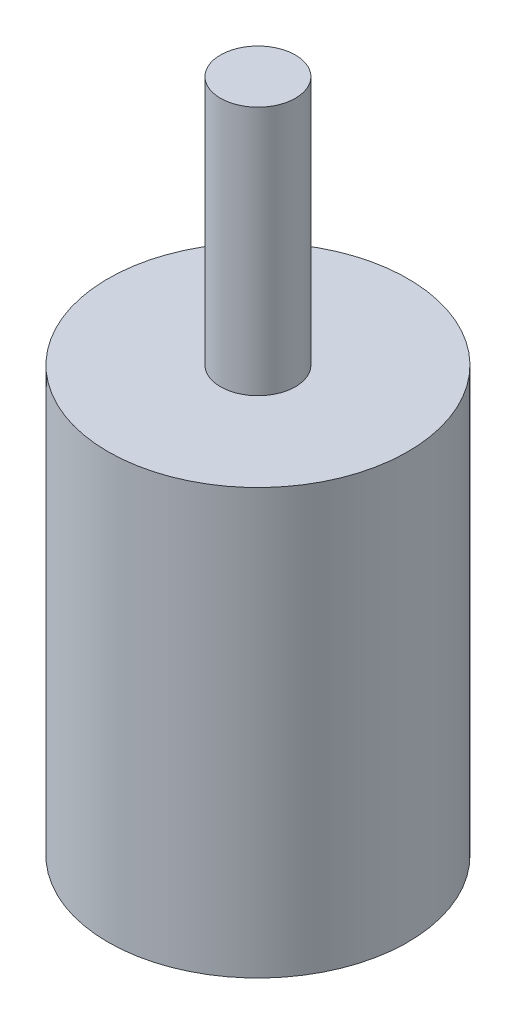
from build123d import *

# Parameters (mm, degrees)
SKETCH1_R           = 12
BOSS_EXTRUDE1_DEPTH = 17
SKETCH2_R           = 3
BOSS_EXTRUDE2_DEPTH = 20


with BuildPart() as part:
    # Sketch1 → Boss-Extrude1 (new body, symmetric)
    with BuildSketch(Plane(origin=(0, 0, 0), x_dir=(1, 0, 0), z_dir=(0, 1, 0))):
        Circle(SKETCH1_R)
    extrude(amount=BOSS_EXTRUDE1_DEPTH, both=True)

    # Sketch2 → Boss-Extrude2 (add)
    with BuildSketch(Plane(origin=(0, 17, 0), x_dir=(1, 0, 0), z_dir=(0, 1, 0))):
        Circle(SKETCH2_R)
    extrude(amount=BOSS_EXTRUDE2_DEPTH)


solid = part.part
